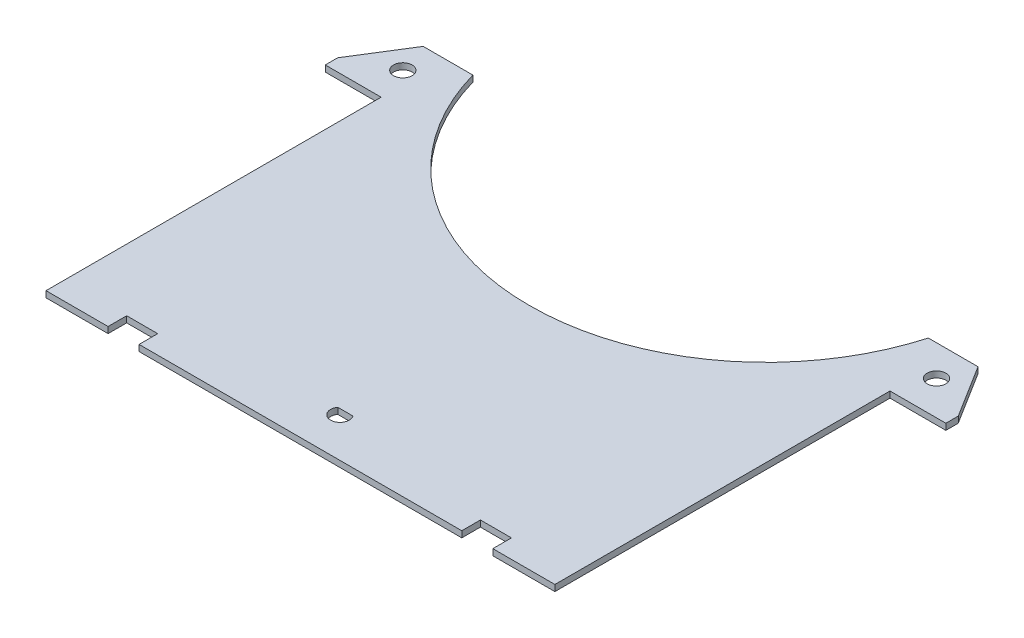
from build123d import *

# Parameters (mm, degrees)
BASE_R                   = 1.5
RESSALTO_EXTRUS_O1_DEPTH = 1


with BuildPart() as part:
    # Base → Ressalto-extrusão1 (new body)
    with BuildSketch(Plane(origin=(0, 0, 0), x_dir=(1, 0, 0), z_dir=(0, 1, 0))):
        with BuildLine():
            Line((0, 56.140303816), (5.299192642, 64.620784778))
            Line((5.299192642, 64.620784778), (13.299192642, 64.620784778))
            ThreePointArc((13.299192642, 64.620784778), (27.008925086, 44.649768212), (50, 37.020302921))
            ThreePointArc((50, 37.020302921), (72.991074914, 44.649768212), (86.700807358, 64.620784778))
            Line((86.700807358, 64.620784778), (94.700807358, 64.620784778))
            Line((94.700807358, 64.620784778), (100, 56.140303816))
            Line((100, 56.140303816), (100, 54.140303816))
            Line((100, 54.140303816), (91, 54.140303816))
            Line((91, 54.140303816), (91, 0.140303816))
            Line((91, 0.140303816), (81, 0.140303816))
            Line((81, 0.140303816), (81, 3.140303816))
            Line((81, 3.140303816), (76, 3.140303816))
            Line((76, 3.140303816), (76, 0.140303816))
            Line((76, 0.140303816), (24, 0.140303816))
            Line((24, 0.140303816), (24, 3.140303816))
            Line((24, 3.140303816), (19, 3.140303816))
            Line((19, 3.140303816), (19, 0.140303816))
            Line((19, 0.140303816), (9, 0.140303816))
            Line((9, 0.140303816), (9, 54.140303816))
            Line((9, 54.140303816), (0, 54.140303816))
            Line((0, 54.140303816), (0, 56.140303816))
        make_face()
        with Locations((7, 59.640303816)):
            Circle(BASE_R, mode=Mode.SUBTRACT)
        with Locations((93, 59.640303816)):
            Circle(BASE_R, mode=Mode.SUBTRACT)
        with BuildLine():
            Line((48.781650707, 7.375), (51.218349293, 7.375))
            ThreePointArc((51.218349293, 7.375), (50, 5), (48.781650707, 7.375))
        make_face(mode=Mode.SUBTRACT)
    extrude(amount=RESSALTO_EXTRUS_O1_DEPTH)


solid = part.part
